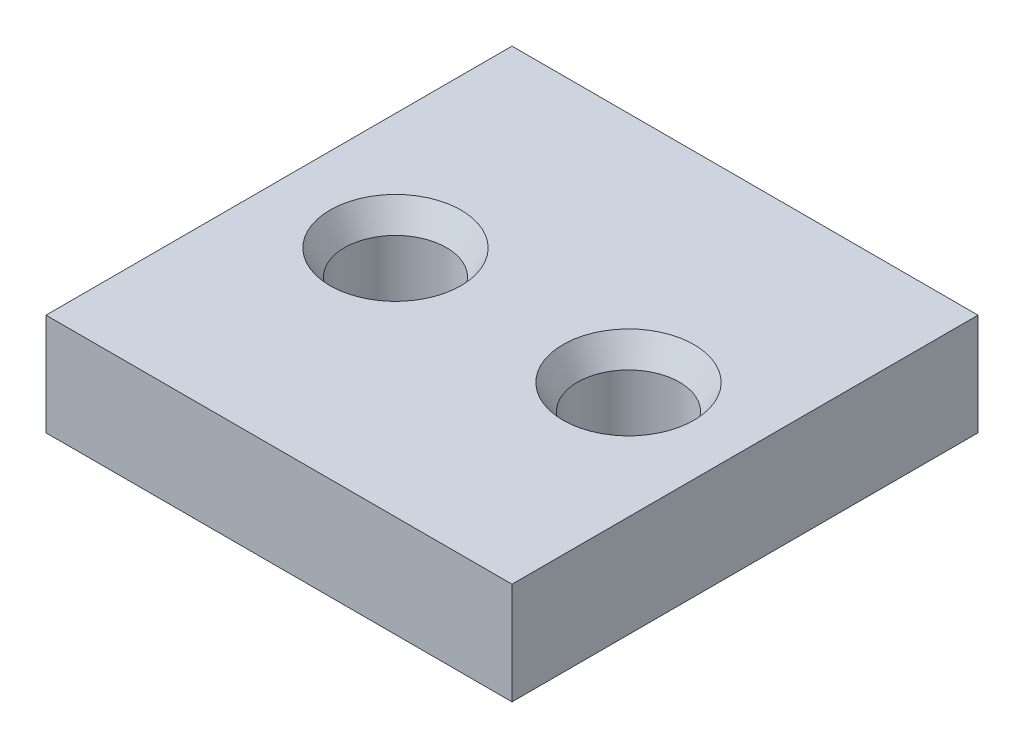
from build123d import *

# Parameters (mm, degrees)
SKETCH1_W                                      = 32
SKETCH1_H                                      = 32
BOSS_EXTRUDE1_DEPTH                            = 7
CSK_FOR_M2_FLAT_HEAD_MACHINE_SCREW1_AT_2_COUNT = 2
CSK_FOR_M2_FLAT_HEAD_MACHINE_SCREW1_AT_2_PITCH = 16


with BuildPart() as part:
    # Sketch1 → Boss-Extrude1 (new body)
    with BuildSketch(Plane(origin=(0, 0, 0), x_dir=(1, 0, 0), z_dir=(0, 1, 0))):
        Rectangle(SKETCH1_W, SKETCH1_H)
    extrude(amount=BOSS_EXTRUDE1_DEPTH)

    # Sketch5 → CSK for M2 Flat Head Machine Screw1 (revolve, cut)
    with BuildSketch(Plane(origin=(-8, 7, 0), x_dir=(0, 0, 1), z_dir=(1, 0, 0))):
        Polygon((0, 0), (0, 7), (3.5, 7), (3.5, 1.732050808), (4.5, 0), align=None)
    csk_for_m2_flat_head_machine_screw1 = revolve(axis=Axis((-8, 13.35, 0), (0, -1, 0)), mode=Mode.SUBTRACT)

    # CSK for M2 Flat Head Machine Screw1 at 2: CSK for M2 Flat Head Machine Screw1 ×2
    with Locations(*[(i * CSK_FOR_M2_FLAT_HEAD_MACHINE_SCREW1_AT_2_PITCH, 0, 0) for i in range(1, CSK_FOR_M2_FLAT_HEAD_MACHINE_SCREW1_AT_2_COUNT)]):
        add(csk_for_m2_flat_head_machine_screw1, mode=Mode.SUBTRACT)


solid = part.part
